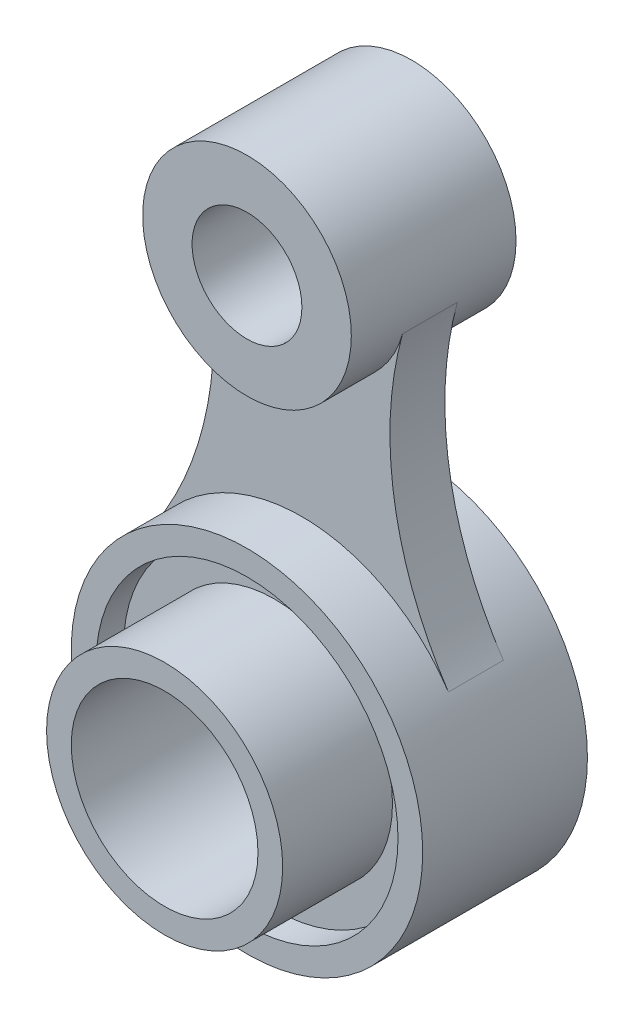
from build123d import *

# Parameters (mm, degrees)
SKETCH1_R             = 32
SKETCH1_R_2           = 27.5
BOSS_EXTRUDE1_DEPTH   = 30
SKETCH1_R_3           = 19
SKETCH1_R_4           = 10
BOSS_EXTRUDE1_2_DEPTH = 30
SKETCH1_3_R           = 27.5
SKETCH1_3_R_2         = 21.5
BOSS_EXTRUDE2_DEPTH   = 25
SKETCH1_4_R           = 21.5
SKETCH1_4_R_2         = 17
BOSS_EXTRUDE3_DEPTH   = 45
BOSS_EXTRUDE4_START   = 10
BOSS_EXTRUDE4_DEPTH   = 10


with BuildPart() as part:
    # Sketch1 → Boss-Extrude1 (new body)
    with BuildSketch(Plane.XY):
        Circle(SKETCH1_R)
        Circle(SKETCH1_R_2, mode=Mode.SUBTRACT)
    extrude(amount=BOSS_EXTRUDE1_DEPTH)

    # Sketch1_3 → Boss-Extrude2 (add)
    with BuildSketch(Plane.XY):
        Circle(SKETCH1_3_R)
        Circle(SKETCH1_3_R_2, mode=Mode.SUBTRACT)
    extrude(amount=BOSS_EXTRUDE2_DEPTH)

    # Sketch1_4 → Boss-Extrude3 (add)
    with BuildSketch(Plane.XY):
        with Locations(Location((0, 0, 0), (0, 0, 180))):
            Circle(SKETCH1_4_R)
        with Locations(Location((0, 0, 0), (0, 0, 180))):
            Circle(SKETCH1_4_R_2, mode=Mode.SUBTRACT)
    extrude(amount=BOSS_EXTRUDE3_DEPTH)



with BuildPart() as body_2:
    # Sketch1 → Boss-Extrude1 2 (new body)
    with BuildSketch(Plane.XY):
        with Locations((0, 75)):
            Circle(SKETCH1_R_3)
        with Locations((0, 75)):
            Circle(SKETCH1_R_4, mode=Mode.SUBTRACT)
    extrude(amount=BOSS_EXTRUDE1_2_DEPTH)


with BuildPart() as part_1:
    add(part.part)

    add(body_2.part)  # Boss-Extrude4 merges body 2
    # Sketch1_5 → Boss-Extrude4 (add)
    with BuildSketch(Plane.XY.offset(BOSS_EXTRUDE4_START)):
        with BuildLine():
            ThreePointArc((18.321243986, 69.966907631), (11.518924537, 59.889924636), (0, 56))
            Line((0, 56), (0, 32))
            ThreePointArc((0, 32), (15.141407538, 28.191093944), (26.678302647, 17.671111111))
            ThreePointArc((26.678302647, 17.671111111), (16.836772686, 42.914041255), (18.321243986, 69.966907631))
        make_face()
        with BuildLine():
            Line((0, 32), (0, 56))
            ThreePointArc((0, 56), (-11.518924537, 59.889924636), (-18.321243986, 69.966907631))
            ThreePointArc((-18.321243986, 69.966907631), (-16.836772686, 42.914041255), (-26.678302647, 17.671111111))
            ThreePointArc((-26.678302647, 17.671111111), (-15.141407538, 28.191093944), (0, 32))
        make_face()
    extrude(amount=BOSS_EXTRUDE4_DEPTH)


solid = part_1.part
